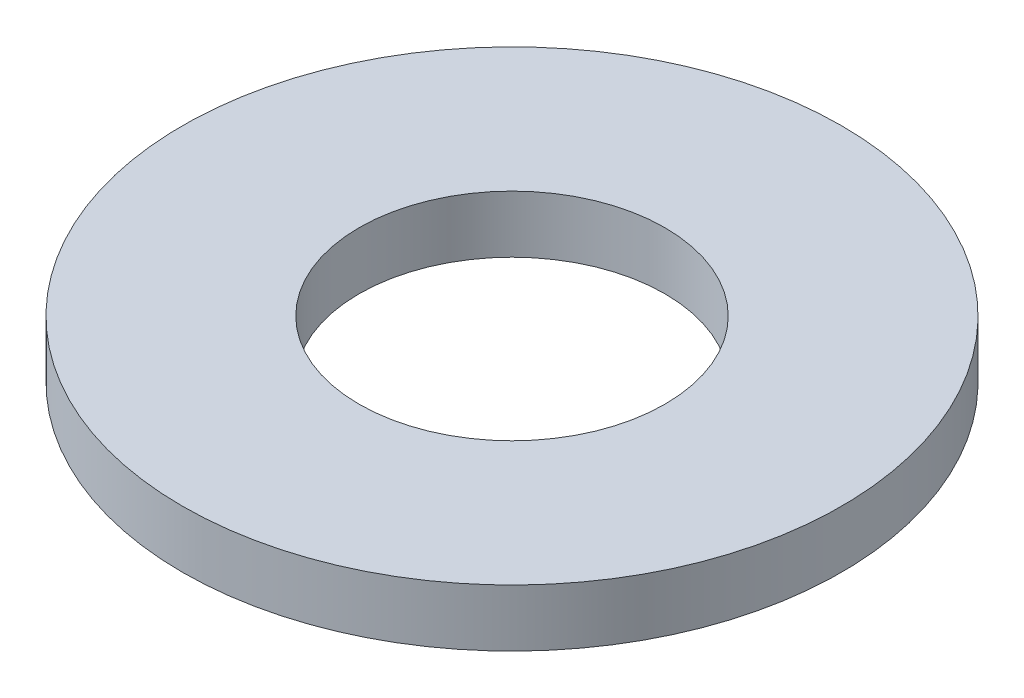
from build123d import *

# Parameters (mm, degrees)
SKETCH1_R           = 5.55625
BOSS_EXTRUDE1_DEPTH = 0.9652
SKETCH5_R           = 2.5781
CUT_EXTRUDE1_DEPTH  = 1.9652


with BuildPart() as part:
    # Sketch1 → Boss-Extrude1 (new body)
    with BuildSketch(Plane(origin=(0, 0, 0), x_dir=(1, 0, 0), z_dir=(0, 1, 0))):
        with Locations(Location((0, 0, 0), (0, 0, 270))):  # turned: the seam where the file's is
            Circle(SKETCH1_R)
    extrude(amount=BOSS_EXTRUDE1_DEPTH)

    # Sketch5 → Cut-Extrude1 (cut, through all)
    with BuildSketch(Plane(origin=(0, 0.9652, 0), x_dir=(-1, 0, 0), z_dir=(0, 1, 0))):
        with Locations(Location((0, 0, 0), (0, 0, 90))):  # turned: the seam where the file's is
            Circle(SKETCH5_R)
    extrude(amount=-CUT_EXTRUDE1_DEPTH, mode=Mode.SUBTRACT)


solid = part.part
